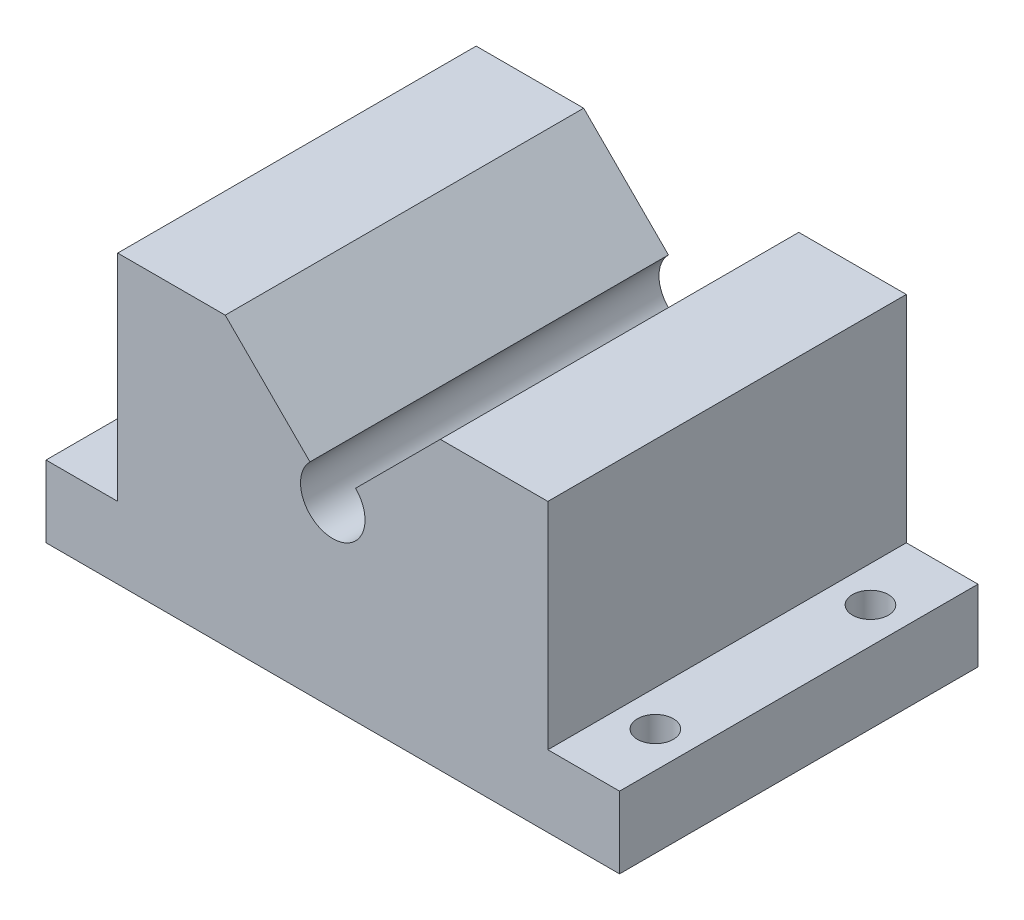
from build123d import *

# Parameters (mm, degrees)
EXTRUDE_1_DEPTH     = 50
SKETCH_5_R          = 4.5
CUT_EXTRUDE_1_DEPTH = 97
SKETCH_6_R          = 2.5
CUT_EXTRUDE_2_DEPTH = 97
SKETCH_7_R          = 2.5
CUT_EXTRUDE_3_DEPTH = 97


with BuildPart() as part:
    # 스케치4 → 보스-돌출1 (new body)
    with BuildSketch(Plane.XY):
        Polygon((40, 0), (0, 0), (-40, 0), (-40, 10), (-30, 10), (-30, 40), (30, 40), (30, 10), (40, 10), align=None)
    extrude(amount=EXTRUDE_1_DEPTH)

    # 스케치5 → 컷-돌출1 (cut)
    with BuildSketch(Plane.XY.offset(50)):
        with Locations((0, 25)):
            Circle(SKETCH_5_R)
        Polygon((0, 25), (15, 40), (-15, 40), align=None)
    extrude(amount=-CUT_EXTRUDE_1_DEPTH, mode=Mode.SUBTRACT)

    # 스케치6 → 컷-돌출2 (cut)
    with BuildSketch(Plane(origin=(0, 10, 0), x_dir=(1, 0, 0), z_dir=(0, 1, 0))):
        with Locations((-35, -10)):
            Circle(SKETCH_6_R)
        with Locations((-35, -40)):
            Circle(SKETCH_6_R)
    extrude(amount=-CUT_EXTRUDE_2_DEPTH, mode=Mode.SUBTRACT)

    # 스케치7 → 컷-돌출3 (cut)
    with BuildSketch(Plane(origin=(0, 10, 0), x_dir=(1, 0, 0), z_dir=(0, 1, 0))):
        with Locations((35, -10)):
            Circle(SKETCH_7_R)
        with Locations((35, -40)):
            Circle(SKETCH_7_R)
    extrude(amount=-CUT_EXTRUDE_3_DEPTH, mode=Mode.SUBTRACT)


solid = part.part
